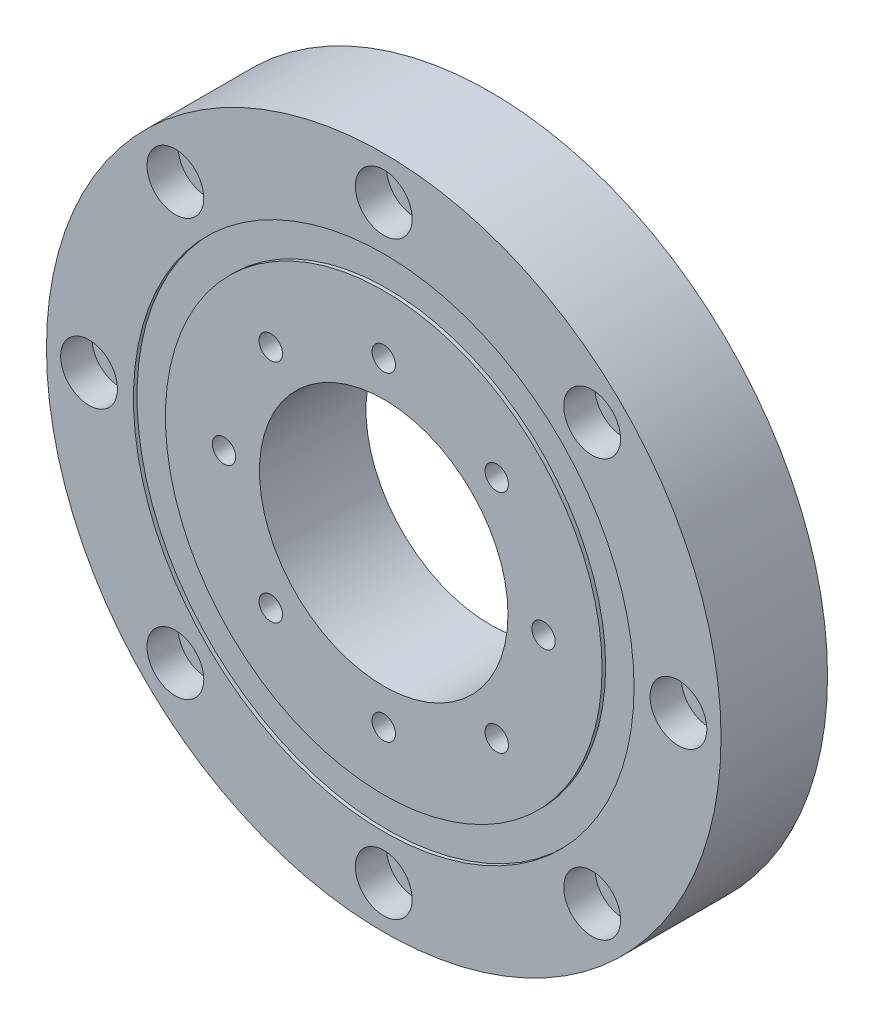
from build123d import *

# Parameters (mm, degrees)
SKETCH_1_R                   = 47.5
EXTRUDE_1_DEPTH              = 7.5
SKETCH_2_R                   = 17.5
CUT_EXTRUDE_1_DEPTH          = 16
SKETCH_3_R                   = 35.25
SKETCH_3_R_2                 = 30.75
CUT_EXTRUDE_2_DEPTH          = 0.5
HOLE_WIZARD_M4_1_D           = 4.5
HOLE_WIZARD_M4_1_CBORE_D     = 8
HOLE_WIZARD_M4_1_CBORE_DEPTH = 4.4
M4X0_7_1_D                   = 3.3
PATTERN_CIRCULAR_1_COUNT     = 8


with BuildPart() as part:
    # 草圖1 → 填料-伸長1 (new body, symmetric)
    with BuildSketch(Plane.XY):
        Circle(SKETCH_1_R)
    extrude(amount=EXTRUDE_1_DEPTH, both=True)

    # 草圖2 → 除料-伸長1 (cut, through all)
    with BuildSketch(Plane.XY.offset(7.5)):
        Circle(SKETCH_2_R)
    extrude(amount=-CUT_EXTRUDE_1_DEPTH, mode=Mode.SUBTRACT)

    # 草圖3 → 除料-伸長2 (cut)
    with BuildSketch(Plane.XY.offset(7.5)):
        Circle(SKETCH_3_R)
        Circle(SKETCH_3_R_2, mode=Mode.SUBTRACT)
    cut_extrude_2 = extrude(amount=-CUT_EXTRUDE_2_DEPTH, mode=Mode.SUBTRACT)

    # 鏡射1: 除料-伸長2 across plane
    add(cut_extrude_2.mirror(Plane.XY), mode=Mode.SUBTRACT)

    # M4 凹頭蓋螺釘的柱孔1 (through all)
    with Locations(Plane.XY.offset(7.5)):
        with Locations((0, 41.5)):
            hole_wizard_m4_1 = CounterBoreHole(HOLE_WIZARD_M4_1_D / 2, HOLE_WIZARD_M4_1_CBORE_D / 2, HOLE_WIZARD_M4_1_CBORE_DEPTH)

    # M4x0.7 螺紋孔1 (through all)
    with Locations(Plane.XY.offset(7.5)):
        with Locations((0, 22.5)):
            m4x0_7_1 = Hole(M4X0_7_1_D / 2)

    # 環狀複製排列1: M4 凹頭蓋螺釘的柱孔1, M4x0.7 螺紋孔1 ×8 about axis
    pattern_circular_1_axis = Axis((0, 0, 0), (0, 0, 1))
    for i in range(1, PATTERN_CIRCULAR_1_COUNT):
        add(hole_wizard_m4_1.rotate(pattern_circular_1_axis, i * 360 / PATTERN_CIRCULAR_1_COUNT), mode=Mode.SUBTRACT)
        add(m4x0_7_1.rotate(pattern_circular_1_axis, i * 360 / PATTERN_CIRCULAR_1_COUNT), mode=Mode.SUBTRACT)


solid = part.part
